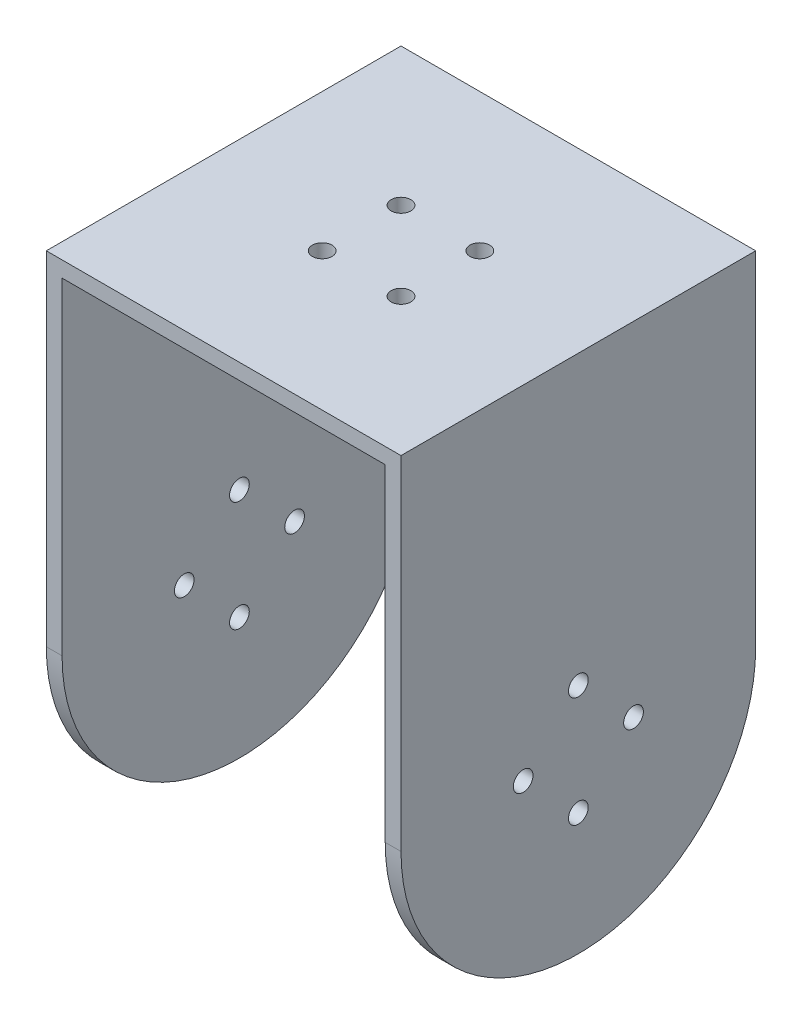
from build123d import *

# Parameters (mm, degrees)
BOSS_EXTRUDE2_DEPTH      = 22.5
BOSS_EXTRUDE2_DEPTH_BACK = 22.5
CUT_EXTRUDE4_DEPTH       = 41.5
CUT_EXTRUDE4_DEPTH_BACK  = 22.5
SKETCH7_W                = 41
SKETCH7_H                = 45
SKETCH8_R                = 1.25
CUT_EXTRUDE5_DEPTH       = 18.5
SKETCH9_R                = 1.25
CUT_EXTRUDE6_DEPTH       = 58.5
SKETCH10_R               = 3.181768177
CUT_EXTRUDE7_DEPTH       = 1


with BuildPart() as part:
    # Sketch6 → Boss-Extrude2 (new, two sides: drawn at the far end of the back side and taken through both)
    with BuildSketch(Plane(origin=(0, 0, 0), x_dir=(0, 0, -1), z_dir=(1, 0, 0)).offset(-BOSS_EXTRUDE2_DEPTH_BACK)):
        with BuildLine():
            Line((-22.5, 0), (-22.5, 43.5))
            Line((-22.5, 43.5), (22.5, 43.5))
            Line((22.5, 43.5), (22.5, 0))
            ThreePointArc((22.5, 0), (0, -22.5), (-22.5, 0))
        make_face()
    extrude(amount=BOSS_EXTRUDE2_DEPTH + BOSS_EXTRUDE2_DEPTH_BACK)

    # Sketch7 → Cut-Extrude4 (cut, two sides: drawn at the far end of the back side and taken through both)
    with BuildSketch(Plane(origin=(0, 0, 0), x_dir=(1, 0, 0), z_dir=(0, 1, 0)).offset(-CUT_EXTRUDE4_DEPTH_BACK)):
        Rectangle(SKETCH7_W, SKETCH7_H)
    extrude(amount=CUT_EXTRUDE4_DEPTH + CUT_EXTRUDE4_DEPTH_BACK, mode=Mode.SUBTRACT)

    # Sketch8 → Cut-Extrude5 (cut)
    with BuildSketch(Plane(origin=(0, 43.5, 0), x_dir=(1, 0, 0), z_dir=(0, 1, 0))):
        with Locations((-5, 5)):
            Circle(SKETCH8_R)
        with Locations((5, -5)):
            Circle(SKETCH8_R)
        with Locations((5, 5)):
            Circle(SKETCH8_R)
        with Locations((-5, -5)):
            Circle(SKETCH8_R)
    extrude(amount=-CUT_EXTRUDE5_DEPTH, mode=Mode.SUBTRACT)

    # Sketch9 → Cut-Extrude6 (cut)
    with BuildSketch(Plane.ZY.offset(22.5)):
        with Locations((0, 7)):
            Circle(SKETCH9_R)
        with Locations((0, -7)):
            Circle(SKETCH9_R)
        with Locations((-7, 0)):
            Circle(SKETCH9_R)
        with Locations((7, 0)):
            Circle(SKETCH9_R)
    extrude(amount=-CUT_EXTRUDE6_DEPTH, mode=Mode.SUBTRACT)

    # Sketch10 → Cut-Extrude7 (cut)
    with BuildSketch(Plane.ZY.offset(22.5)):
        Circle(SKETCH10_R)
    extrude(amount=-CUT_EXTRUDE7_DEPTH, mode=Mode.SUBTRACT)


solid = part.part
